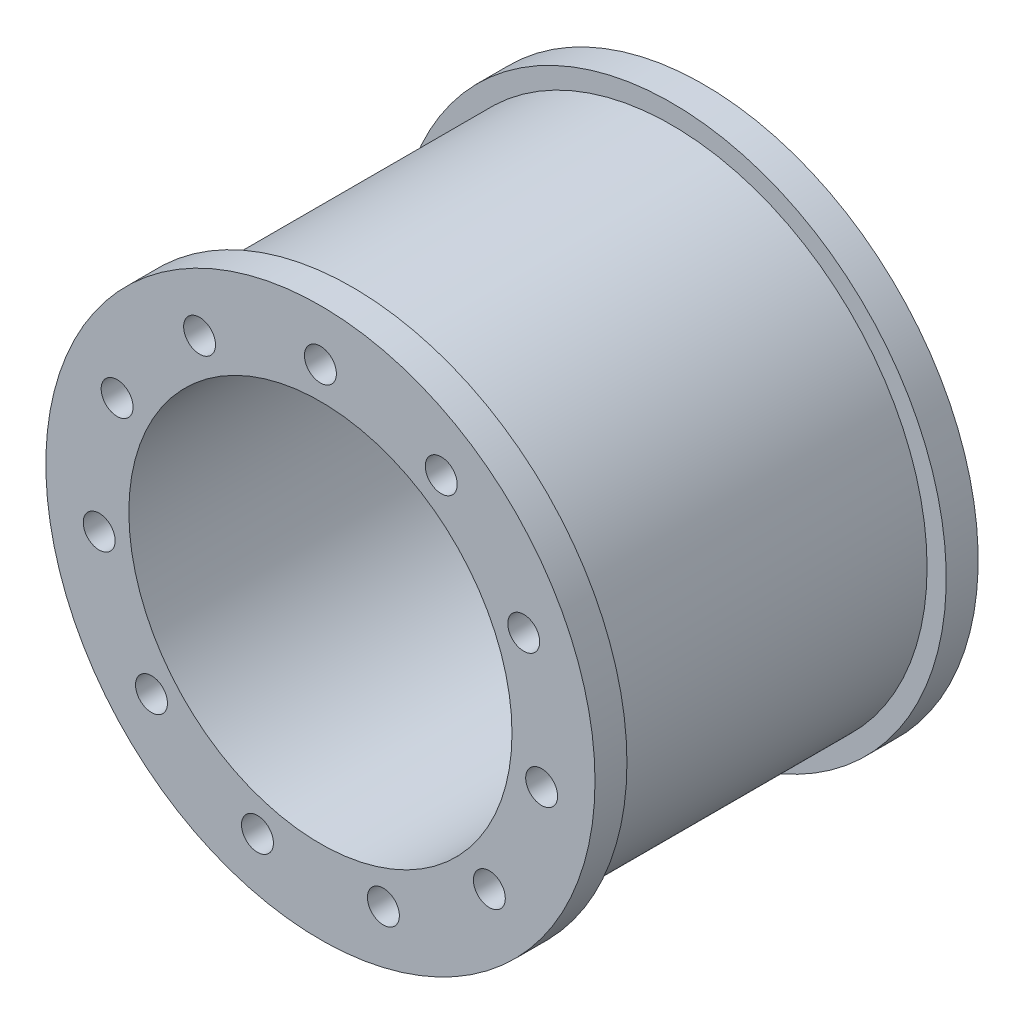
from build123d import *

# Parameters (mm, degrees)
SKETCH1_R           = 40
SKETCH1_R_2         = 30
SKETCH1_R_3         = 2.5
BOSS_EXTRUDE1_DEPTH = 50
SKETCH2_R           = 43
SKETCH2_R_2         = 30
BOSS_EXTRUDE2_DEPTH = 5
SKETCH3_R           = 43
SKETCH3_R_2         = 30
SKETCH3_R_3         = 2.5
BOSS_EXTRUDE3_DEPTH = 5


with BuildPart() as part:
    # Sketch1 → Boss-Extrude1 (new body)
    with BuildSketch(Plane.XY):
        Circle(SKETCH1_R)
        Circle(SKETCH1_R_2, mode=Mode.SUBTRACT)
        with Locations((0, 35)):
            Circle(SKETCH1_R_3, mode=Mode.SUBTRACT)
        with Locations((18.922428611, 29.443873649)):
            Circle(SKETCH1_R_3, mode=Mode.SUBTRACT)
        with Locations((31.837119837, 14.539525455)):
            Circle(SKETCH1_R_3, mode=Mode.SUBTRACT)
        with Locations((34.643750466, -4.98101934)):
            Circle(SKETCH1_R_3, mode=Mode.SUBTRACT)
        with Locations((26.451235102, -22.920125688)):
            Circle(SKETCH1_R_3, mode=Mode.SUBTRACT)
        with Locations((9.860639489, -33.582254077)):
            Circle(SKETCH1_R_3, mode=Mode.SUBTRACT)
        with Locations((-9.860639489, -33.582254077)):
            Circle(SKETCH1_R_3, mode=Mode.SUBTRACT)
        with Locations((-26.451235102, -22.920125688)):
            Circle(SKETCH1_R_3, mode=Mode.SUBTRACT)
        with Locations((-34.643750466, -4.98101934)):
            Circle(SKETCH1_R_3, mode=Mode.SUBTRACT)
        with Locations((-31.837119837, 14.539525455)):
            Circle(SKETCH1_R_3, mode=Mode.SUBTRACT)
        with Locations((-18.922428611, 29.443873649)):
            Circle(SKETCH1_R_3, mode=Mode.SUBTRACT)
    extrude(amount=BOSS_EXTRUDE1_DEPTH)

    # Sketch2 → Boss-Extrude2 (add)
    with BuildSketch(Plane(origin=(0, 0, 0), x_dir=(-1, 0, 0), z_dir=(0, 0, -1))):
        Circle(SKETCH2_R)
        Circle(SKETCH2_R_2, mode=Mode.SUBTRACT)
    extrude(amount=BOSS_EXTRUDE2_DEPTH)

    # Sketch3 → Boss-Extrude3 (add)
    with BuildSketch(Plane.XY.offset(50)):
        Circle(SKETCH3_R)
        Circle(SKETCH3_R_2, mode=Mode.SUBTRACT)
        with Locations((31.837119837, 14.539525455)):
            Circle(SKETCH3_R_3, mode=Mode.SUBTRACT)
        with Locations((34.643750466, -4.98101934)):
            Circle(SKETCH3_R_3, mode=Mode.SUBTRACT)
        with Locations((26.451235102, -22.920125688)):
            Circle(SKETCH3_R_3, mode=Mode.SUBTRACT)
        with Locations((9.860639489, -33.582254077)):
            Circle(SKETCH3_R_3, mode=Mode.SUBTRACT)
        with Locations((-9.860639489, -33.582254077)):
            Circle(SKETCH3_R_3, mode=Mode.SUBTRACT)
        with Locations((-26.451235102, -22.920125688)):
            Circle(SKETCH3_R_3, mode=Mode.SUBTRACT)
        with Locations((-34.643750466, -4.98101934)):
            Circle(SKETCH3_R_3, mode=Mode.SUBTRACT)
        with Locations((-31.837119837, 14.539525455)):
            Circle(SKETCH3_R_3, mode=Mode.SUBTRACT)
        with Locations((-18.922428611, 29.443873649)):
            Circle(SKETCH3_R_3, mode=Mode.SUBTRACT)
        with Locations((0, 35)):
            Circle(SKETCH3_R_3, mode=Mode.SUBTRACT)
        with Locations((18.922428611, 29.443873649)):
            Circle(SKETCH3_R_3, mode=Mode.SUBTRACT)
    extrude(amount=BOSS_EXTRUDE3_DEPTH)


solid = part.part
